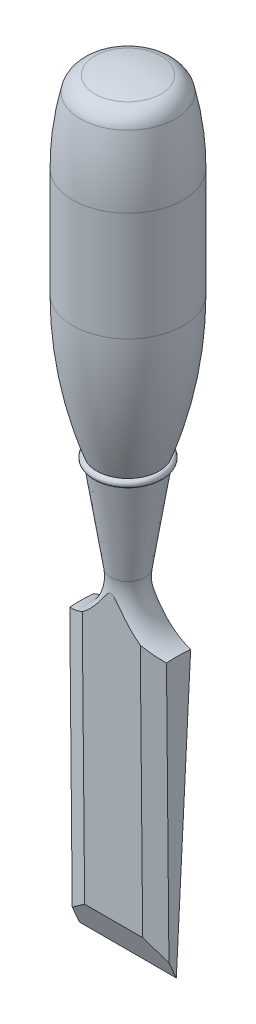
from build123d import *

# Parameters (mm, degrees)
CUT_EXTRUDE1_DEPTH      = 17.51
CUT_EXTRUDE1_DEPTH_BACK = 17.51
SKETCH3_W               = 12.7
SKETCH3_H               = 93.345
CUT_EXTRUDE2_DEPTH      = 15.4780001
CUT_EXTRUDE2_DEPTH_BACK = 15.4780001
CHAMFER1_SIZE           = 1.778
CHAMFER1_SIZE2          = 5.08
CHAMFER1_PART_2_SIZE    = 1.778
CHAMFER1_PART_2_SIZE2   = 5.08


with BuildPart() as part:
    # Sketch1 → Revolve1 (revolve)
    with BuildSketch(Plane.XY):
        with BuildLine():
            Line((0, 0), (0, 200.025))
            ThreePointArc((0, 200.025), (4.361173486, 199.774572862), (8.665015939, 199.026583508))
            ThreePointArc((8.665015939, 199.026583508), (11.099058165, 197.674530854), (12.454800514, 195.242541829))
            ThreePointArc((12.454800514, 195.242541829), (13.970510195, 186.579743755), (14.478, 177.8))
            Line((14.478, 177.8), (14.478, 149.225))
            ThreePointArc((14.478, 149.225), (12.894697981, 130.856561666), (8.1915, 113.03))
            ThreePointArc((8.1915, 113.03), (9.144, 112.0775), (8.1915, 111.125))
            Line((8.1915, 111.125), (4.4958, 86.995))
            ThreePointArc((4.4958, 86.995), (7.228457253, 76.949471101), (16.51, 72.234279615))
            Line((16.51, 72.234279615), (16.51, 0))
            Line((16.51, 0), (0, 0))
        make_face()
    revolve(axis=Axis((0, 0, 0), (0, -1, 0)))

    # Sketch2 → Cut-Extrude1 (cut, two sides)
    with BuildSketch(Plane(origin=(0, 0, 0), x_dir=(0, 0, -1), z_dir=(1, 0, 0))) as cut_extrude1_sk:
        Polygon((4.4958, 86.995), (0, 0), (-3.756857541, 8.509), (-4.4958, 86.995), (-31.75, 86.995), (-31.75, -12.7), (31.75, -12.7), (31.75, 86.995), align=None)
    extrude(amount=CUT_EXTRUDE1_DEPTH, mode=Mode.SUBTRACT)
    extrude(cut_extrude1_sk.sketch, amount=-CUT_EXTRUDE1_DEPTH_BACK, mode=Mode.SUBTRACT)

    # Sketch3 → Cut-Extrude2 (cut, two sides)
    with BuildSketch(Plane.XY) as cut_extrude2_sk:
        with Locations((19.05, 40.3225)):
            Rectangle(SKETCH3_W, SKETCH3_H)
        with Locations((-19.05, 40.3225)):
            Rectangle(SKETCH3_W, SKETCH3_H)
    extrude(amount=CUT_EXTRUDE2_DEPTH, mode=Mode.SUBTRACT)
    extrude(cut_extrude2_sk.sketch, amount=-CUT_EXTRUDE2_DEPTH_BACK, mode=Mode.SUBTRACT)

    # Chamfer1
    chamfer1_edges = [part.edges().sort_by_distance(p)[0] for p in [
        (-12.7, 40.643568714, 4.059403183),
    ]]
    chamfer1_side = [part.faces().sort_by_distance(p)[0] for p in [
        (-12.7, 42.502487943, 0.913030027),
    ]]
    chamfer(chamfer1_edges, length=CHAMFER1_SIZE, length2=CHAMFER1_SIZE2, reference=chamfer1_side[0])

    # Chamfer1 part 2
    chamfer1_part_2_edges = [part.edges().sort_by_distance(p)[0] for p in [
        (12.7, 40.643568715, 4.059403183),
    ]]
    chamfer1_part_2_side = [part.faces().sort_by_distance(p)[0] for p in [
        (12.7, 42.502487941, 0.913030027),
    ]]
    chamfer(chamfer1_part_2_edges, length=CHAMFER1_PART_2_SIZE, length2=CHAMFER1_PART_2_SIZE2, reference=chamfer1_part_2_side[0])


solid = part.part
